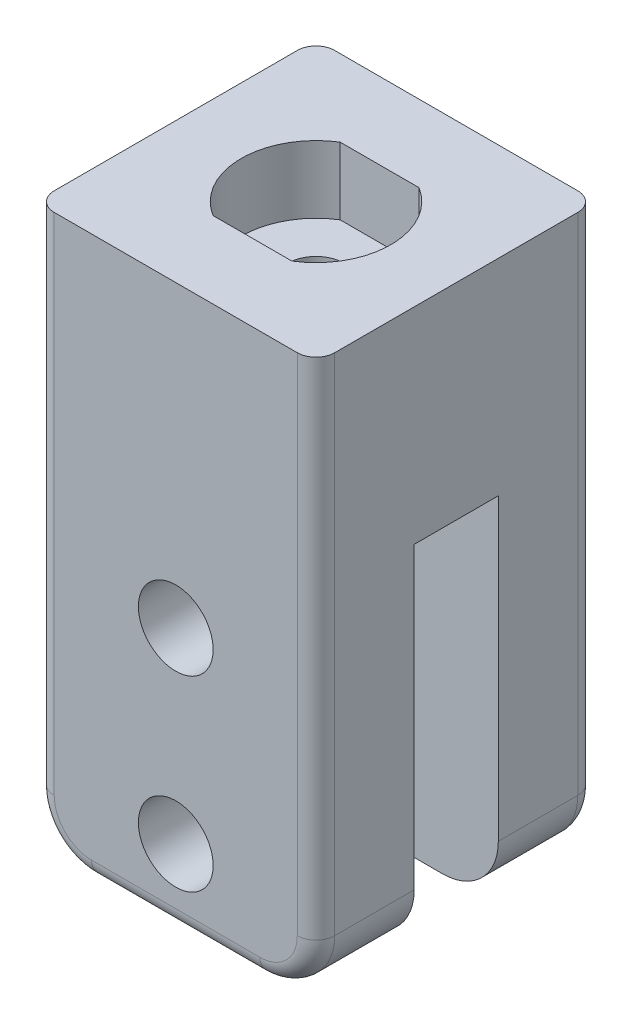
from build123d import *

# Parameters (mm, degrees)
SKETCH2_W               = 15
SKETCH2_H               = 15
BOSS_EXTRUDE3_DEPTH     = 30
SKETCH1_R               = 2
CUT_EXTRUDE1_DEPTH      = 35.369317712
CUT_EXTRUDE2_DEPTH      = 32.819805153
CUT_EXTRUDE2_DEPTH_BACK = 32.819805153
SKETCH3_W               = 4.5
SKETCH3_H               = 19
SKETCH5_R               = 1.5
CUT_EXTRUDE3_DEPTH      = 3.6
SKETCH5_2_R             = 1.5
CUT_EXTRUDE4_DEPTH      = 32.819805153
FILLET3_R               = 3
FILLET1_R               = 1
CUT_EXTRUDE5_DEPTH      = 22.760055147
CUT_EXTRUDE5_DEPTH_BACK = 3.25
SKETCH6_R               = 2.8


with BuildPart() as part:
    # Sketch2 → Boss-Extrude3 (new body)
    with BuildSketch(Plane(origin=(0, 0, 0), x_dir=(1, 0, 0), z_dir=(0, 1, 0))):
        Rectangle(SKETCH2_W, SKETCH2_H)
    extrude(amount=BOSS_EXTRUDE3_DEPTH)

    # Sketch1 → Cut-Extrude1 (cut, through all)
    with BuildSketch(Plane.XY.offset(7.5)):
        with Locations((0, 4)):
            Circle(SKETCH1_R)
        with Locations((0, 14)):
            Circle(SKETCH1_R)
    extrude(amount=-CUT_EXTRUDE1_DEPTH, mode=Mode.SUBTRACT)

    # Sketch3 → Cut-Extrude2 (cut, two sides: drawn at the far end of the back side and taken through both)
    with BuildSketch(Plane(origin=(0, 0, 0), x_dir=(0, 0, -1), z_dir=(1, 0, 0)).offset(-CUT_EXTRUDE2_DEPTH_BACK)):
        with Locations((0, 9.5)):
            Rectangle(SKETCH3_W, SKETCH3_H)
    extrude(amount=CUT_EXTRUDE2_DEPTH + CUT_EXTRUDE2_DEPTH_BACK, mode=Mode.SUBTRACT)

    # Sketch5 → Cut-Extrude3 (cut)
    with BuildSketch(Plane(origin=(0, 30, 0), x_dir=(1, 0, 0), z_dir=(0, 1, 0))):
        with BuildLine():
            Line((-2.107130751, -3.4), (2.107130751, -3.4))
            ThreePointArc((2.107130751, -3.4), (4, 0), (2.107130751, 3.4))
            Line((2.107130751, 3.4), (-2.107130751, 3.4))
            ThreePointArc((-2.107130751, 3.4), (-4, 0), (-2.107130751, -3.4))
        make_face()
        Circle(SKETCH5_R, mode=Mode.SUBTRACT)
    extrude(amount=-CUT_EXTRUDE3_DEPTH, mode=Mode.SUBTRACT)

    # Sketch5_2 → Cut-Extrude4 (cut, through all)
    with BuildSketch(Plane(origin=(0, 30, 0), x_dir=(1, 0, 0), z_dir=(0, 1, 0))):
        Circle(SKETCH5_2_R)
    extrude(amount=-CUT_EXTRUDE4_DEPTH, mode=Mode.SUBTRACT)

    # Fillet3
    fillet3_edges = [part.edges().sort_by_distance(p)[0] for p in [
        (-7.5, 0, -4.875),
        (7.5, 0, -4.875),
        (7.5, 0, 4.875),
        (-7.5, 0, 4.875),
    ]]
    fillet(fillet3_edges, radius=FILLET3_R)

    # Fillet1
    fillet1_edges = [part.edges().sort_by_distance(p)[0] for p in [
        (7.5, 16.5, 7.5),
        (-7.5, 16.5, -7.5),
        (7.5, 16.5, -7.5),
        (-7.5, 16.5, 7.5),
        (0, 0, -7.5),
        (0, 0, 7.5),
        (-6.621320344, 0.878679656, -7.5),
        (6.621320344, 0.878679656, -7.5),
        (6.621320344, 0.878679656, 7.5),
        (-6.621320344, 0.878679656, 7.5),
    ]]
    fillet(fillet1_edges, radius=FILLET1_R)

    # Sketch6 → Cut-Extrude5 (cut, two sides: drawn at the far end of the back side and taken through both)
    with BuildSketch(Plane.XZ.offset(-19).offset(-CUT_EXTRUDE5_DEPTH_BACK)):
        Circle(SKETCH6_R)
    extrude(amount=CUT_EXTRUDE5_DEPTH + CUT_EXTRUDE5_DEPTH_BACK, mode=Mode.SUBTRACT)


solid = part.part
